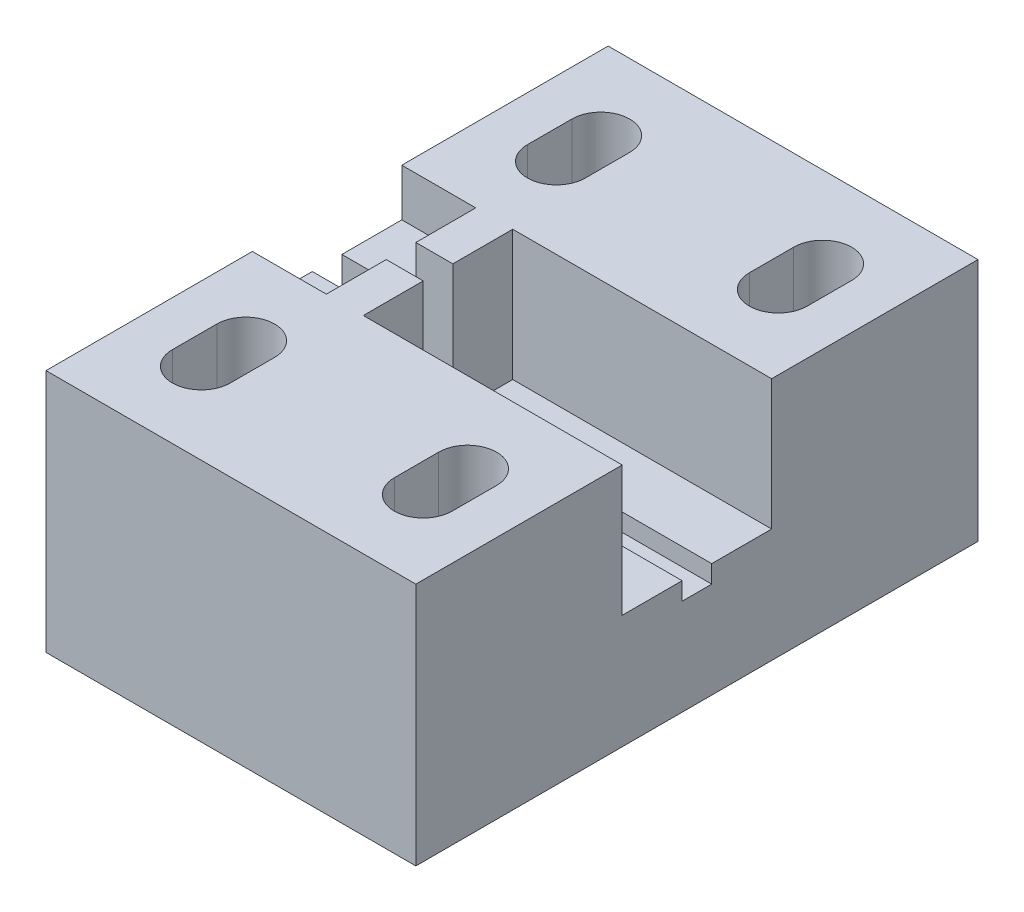
from build123d import *

# Parameters (mm, degrees)
SKETCH1_W               = 25
SKETCH1_H               = 38
BOSS_EXTRUDE1_DEPTH     = 16.5
F_6_32_SLOTS_DEPTH      = 17.5
SKETCH2_11_W            = 5
SKETCH2_11_H            = 5.05
LENS_SEAT_DEPTH         = 3.2
SKETCH2_13_W            = 17.5
SKETCH2_13_H            = 10.1
LENS_PLATE_GROOVE_DEPTH = 8.8
SKETCH6_W               = 25
SKETCH6_H               = 2
ALIGNMENT_GROOVE_DEPTH  = 10
F_4_40_TAPPED_HOLE2_D   = 2.2606


with BuildPart() as part:
    # Sketch1 → Boss-Extrude1 (new body)
    with BuildSketch(Plane(origin=(0, 0, 0), x_dir=(1, 0, 0), z_dir=(0, 1, 0))):
        with Locations((-18481.446731235, 11298.191283293)):
            Rectangle(SKETCH1_W, SKETCH1_H)
    extrude(amount=BOSS_EXTRUDE1_DEPTH)

    # Sketch2 → 6-32 slots (cut, through all)
    with BuildSketch(Plane(origin=(0, 16.5, 0), x_dir=(1, 0, 0), z_dir=(0, 1, 0))):
        with BuildLine():
            Line((-18486.991731235, 11311.691283293), (-18486.991731235, 11308.691283293))
            ThreePointArc((-18486.991731235, 11308.691283293), (-18488.946731235, 11306.736283293), (-18490.901731235, 11308.691283293))
            Line((-18490.901731235, 11308.691283293), (-18490.901731235, 11311.691283293))
            ThreePointArc((-18490.901731235, 11311.691283293), (-18488.946731235, 11313.646283293), (-18486.991731235, 11311.691283293))
        make_face()
        with BuildLine():
            Line((-18486.991731235, 11284.691283293), (-18486.991731235, 11287.691283293))
            ThreePointArc((-18486.991731235, 11287.691283293), (-18488.946731235, 11289.646283293), (-18490.901731235, 11287.691283293))
            Line((-18490.901731235, 11287.691283293), (-18490.901731235, 11284.691283293))
            ThreePointArc((-18490.901731235, 11284.691283293), (-18488.946731235, 11282.736283293), (-18486.991731235, 11284.691283293))
        make_face()
        with BuildLine():
            Line((-18475.901731235, 11284.691283293), (-18475.901731235, 11287.691283293))
            ThreePointArc((-18475.901731235, 11287.691283293), (-18473.946731235, 11289.646283293), (-18471.991731235, 11287.691283293))
            Line((-18471.991731235, 11287.691283293), (-18471.991731235, 11284.691283293))
            ThreePointArc((-18471.991731235, 11284.691283293), (-18473.946731235, 11282.736283293), (-18475.901731235, 11284.691283293))
        make_face()
        with BuildLine():
            Line((-18475.901731235, 11311.691283293), (-18475.901731235, 11308.691283293))
            ThreePointArc((-18475.901731235, 11308.691283293), (-18473.946731235, 11306.736283293), (-18471.991731235, 11308.691283293))
            Line((-18471.991731235, 11308.691283293), (-18471.991731235, 11311.691283293))
            ThreePointArc((-18471.991731235, 11311.691283293), (-18473.946731235, 11313.646283293), (-18475.901731235, 11311.691283293))
        make_face()
    extrude(amount=-F_6_32_SLOTS_DEPTH, mode=Mode.SUBTRACT)

    # Sketch2_11 → lens seat (cut)
    with BuildSketch(Plane(origin=(0, 16.5, 0), x_dir=(1, 0, 0), z_dir=(0, 1, 0))):
        Polygon((-18493.946731235, 11300.191283293), (-18493.946731235, 11298.191283293), (-18488.946731235, 11298.191283293), (-18488.946731235, 11303.241283293), (-18493.946731235, 11303.241283293), align=None)
        with Locations((-18491.446731235, 11295.666283293)):
            Rectangle(SKETCH2_11_W, SKETCH2_11_H)
    extrude(amount=-LENS_SEAT_DEPTH, mode=Mode.SUBTRACT)

    # Sketch2_13 → lens plate groove (cut)
    with BuildSketch(Plane(origin=(0, 16.5, 0), x_dir=(1, 0, 0), z_dir=(0, 1, 0))):
        with Locations((-18477.696731235, 11298.191283293)):
            Rectangle(SKETCH2_13_W, SKETCH2_13_H)
    extrude(amount=-LENS_PLATE_GROOVE_DEPTH, mode=Mode.SUBTRACT)

    # Sketch6 → alignment groove (cut)
    with BuildSketch(Plane(origin=(0, 16.5, 0), x_dir=(1, 0, 0), z_dir=(0, 1, 0))):
        with Locations((-18481.446731235, 11298.191283293)):
            Rectangle(SKETCH6_W, SKETCH6_H)
    extrude(amount=-ALIGNMENT_GROOVE_DEPTH, mode=Mode.SUBTRACT)

    # 4-40 Tapped Hole2 (through all)
    with Locations(Plane(origin=(0, 7.7, 0), x_dir=(1, 0, 0), z_dir=(0, 1, 0))):
        with Locations((-18481.946731235, 11298.191283293)):
            Hole(F_4_40_TAPPED_HOLE2_D / 2)


solid = part.part
